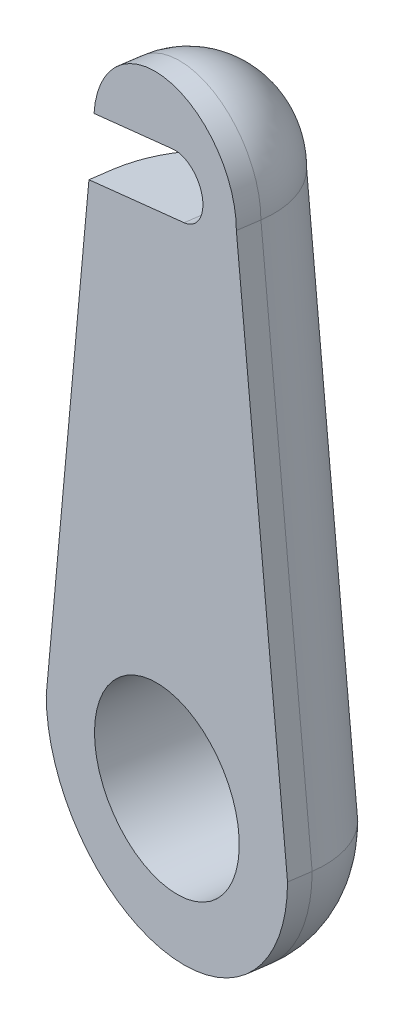
from build123d import *

# Parameters (mm, degrees)
BASE_EXTRUDE_DEPTH = 6.35
FILLET1_R          = 5
CUT_EXTRUDE1_START = -6.35
CUT_EXTRUDE1_DEPTH = 6.350746
SKETCH4_R          = 5.334
CUT_EXTRUDE2_DEPTH = 6.35


with BuildPart() as part:
    # Sketch1 → Base Extrude (new body)
    with BuildSketch(Plane(origin=(8.114628625, -3.283425705, -55.67660861), x_dir=(-0.989545354, 0, -0.144222022), z_dir=(0.144222022, 0, -0.989545354))):
        with BuildLine():
            Line((-1.106091457, 205.484448373), (2.665349365, 238.484448373))
            ThreePointArc((2.665349365, 238.484448373), (7.915349365, 243.734448373), (13.165349365, 238.484448373))
            Line((13.165349365, 238.484448373), (16.673908543, 205.484448373))
            ThreePointArc((16.673908543, 205.484448373), (7.783908543, 196.594448373), (-1.106091457, 205.484448373))
        make_face()
    extrude(amount=BASE_EXTRUDE_DEPTH)

    # Fillet1
    fillet1_edges = [part.edges().sort_by_distance(p)[0] for p in [
        (-5.733211058, 218.701022668, -64.111960662),
        (1.327907925, 193.311022668, -63.082832637),
        (8.258960253, 218.701022668, -62.072661274),
        (1.19784127, 240.451022668, -63.101789298),
    ]]
    fillet(fillet1_edges, radius=FILLET1_R)

    # Sketch3 → Cut-Extrude1 (cut)
    with BuildSketch(Plane(origin=(9.030438463, -3.283425705, -61.96022161), x_dir=(-0.989545354, 0, -0.144222022), z_dir=(0.144222022, 0, -0.989545354)).offset(CUT_EXTRUDE1_START)):
        with BuildLine():
            Line((14.3026167, 234.886394841), (6.516843813, 236.725345777))
            ThreePointArc((6.516843813, 236.725345777), (5.178808874, 238.890908637), (7.344371734, 240.228943576))
            Line((7.344371734, 240.228943576), (15.130144622, 238.38999264))
            ThreePointArc((15.130144622, 238.38999264), (16.468179561, 236.22442978), (14.3026167, 234.886394841))
        make_face()
    extrude(amount=CUT_EXTRUDE1_DEPTH, mode=Mode.SUBTRACT)


with BuildPart() as body_2:
    # Mirror2: mirrored copy
    add(part.part.mirror(Plane(origin=(-103.213448145, 0, -15.042920567), x_dir=(-0.144222022, 0, 0.989545354), z_dir=(0.989545354, 0, 0.144222022))))


with BuildPart() as part_1:
    add(part.part)

    # Sketch4 → Cut-Extrude2 (cut)
    with BuildSketch(Plane(origin=(9.030438463, 0, -61.96022161), x_dir=(-0.989545354, 0, -0.144222022), z_dir=(0.144222022, 0, -0.989545354))):
        with Locations((7.783908543, 202.201022668)):
            Circle(SKETCH4_R)
    cut_extrude2 = extrude(amount=-CUT_EXTRUDE2_DEPTH, mode=Mode.SUBTRACT)


with BuildPart() as body_2_1:
    add(body_2.part)

    # Mirror3: Cut-Extrude2 across plane
    add(cut_extrude2.mirror(Plane(origin=(-103.213448145, 0, -15.042920567), x_dir=(-0.144222022, 0, 0.989545354), z_dir=(0.989545354, 0, 0.144222022))), mode=Mode.SUBTRACT)


solid = part_1.part
